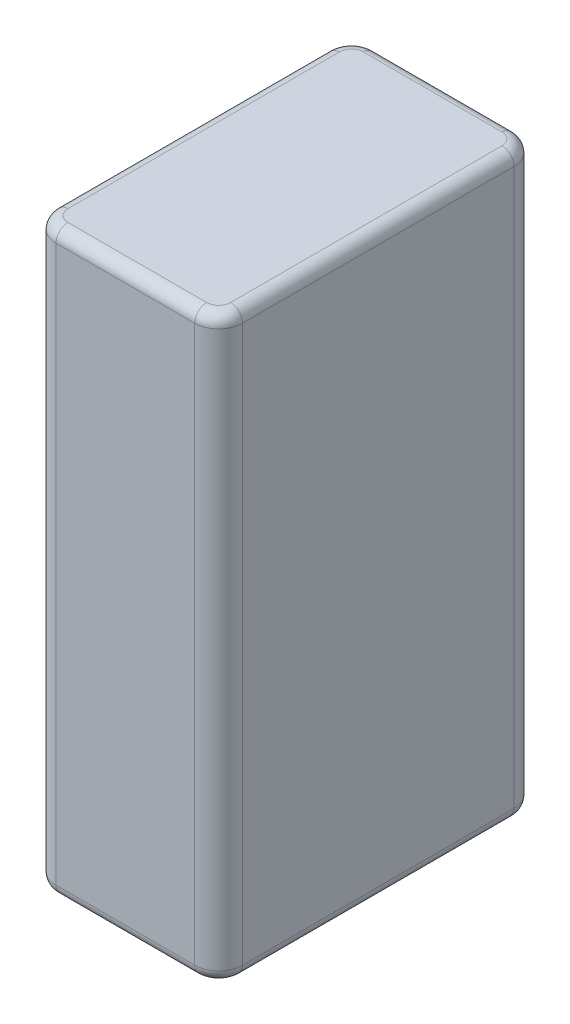
from build123d import *

# Parameters (mm, degrees)
SKETCH1_W      = 15.6
SKETCH1_H      = 26.7
EXTRUDE1_DEPTH = 48.5
FILLET1_R      = 2
FILLET2_R      = 1


with BuildPart() as part:
    # Sketch1 → Extrude1 (new body)
    with BuildSketch(Plane(origin=(0, 0, 0), x_dir=(1, 0, 0), z_dir=(0, 1, 0))):
        Rectangle(SKETCH1_W, SKETCH1_H)
    extrude(amount=EXTRUDE1_DEPTH)

    # Fillet1
    fillet1_edges = [part.edges().sort_by_distance(p)[0] for p in [
        (-7.8, 24.25, -13.35),
        (7.8, 24.25, -13.35),
        (7.8, 24.25, 13.35),
        (-7.8, 24.25, 13.35),
    ]]
    fillet(fillet1_edges, radius=FILLET1_R)

    # Fillet2
    fillet2_edges = [part.edges().sort_by_distance(p)[0] for p in [
        (0, 0, 13.35),
        (0, 48.5, 13.35),
        (-7.8, 0, 0),
        (0, 0, -13.35),
        (7.8, 0, 0),
        (7.214213562, 0, 12.764213562),
        (7.214213562, 0, -12.764213562),
        (-7.214213562, 0, -12.764213562),
        (-7.214213562, 0, 12.764213562),
        (-7.8, 48.5, 0),
        (7.8, 48.5, 0),
        (0, 48.5, -13.35),
        (7.214213562, 48.5, 12.764213562),
        (7.214213562, 48.5, -12.764213562),
        (-7.214213562, 48.5, -12.764213562),
        (-7.214213562, 48.5, 12.764213562),
    ]]
    fillet(fillet2_edges, radius=FILLET2_R)


solid = part.part
